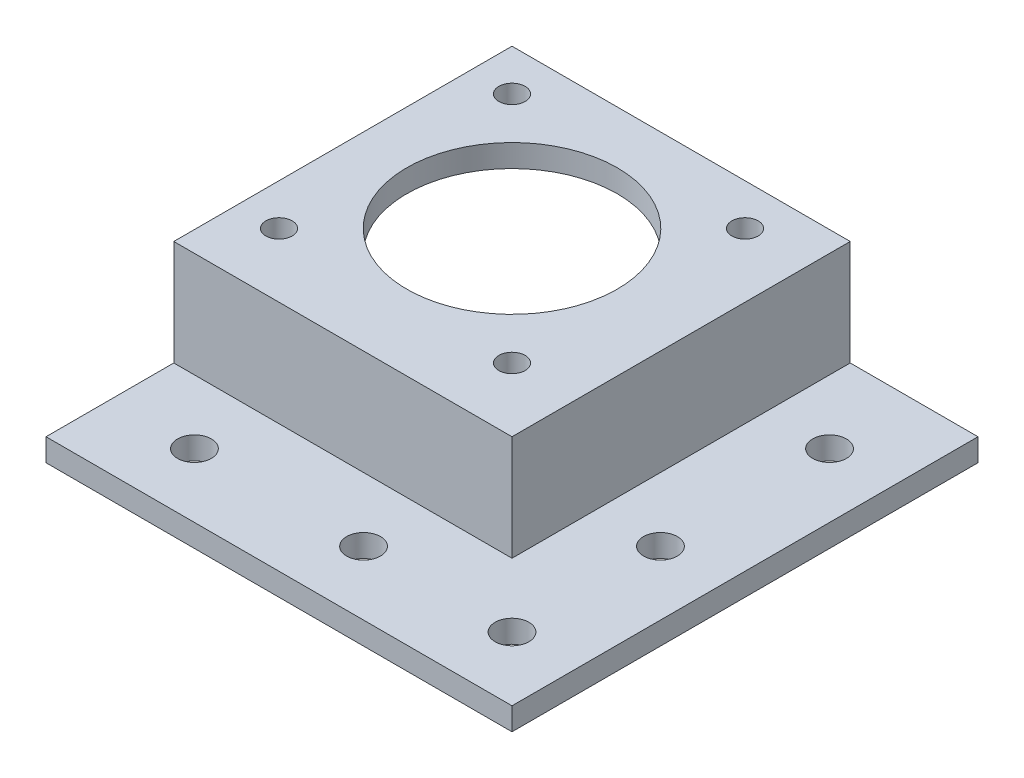
from build123d import *

# Parameters (mm, degrees)
BOSS_EXTRUDE6_DEPTH = 42
SKETCH9_W           = 42
SKETCH9_H           = 14
BOSS_EXTRUDE7_DEPTH = 3
SKETCH10_W          = 62
SKETCH10_H          = 3
BOSS_EXTRUDE8_DEPTH = 17
SKETCH11_R          = 1.75
SKETCH11_R_2        = 14
CUT_EXTRUDE3_DEPTH  = 4
SKETCH12_R          = 2.25
CUT_EXTRUDE4_DEPTH  = 4


with BuildPart() as part:
    # Sketch7 → Boss-Extrude6 (new body)
    with BuildSketch(Plane.XY):
        Polygon((42, -17), (62, -17), (62, -14), (45, -14), (45, 0), (0, 0), (0, -3), (42, -3), align=None)
    extrude(amount=BOSS_EXTRUDE6_DEPTH)

    # Sketch9 → Boss-Extrude7 (add)
    with BuildSketch(Plane.XY.offset(42)):
        with Locations((21, -10)):
            Rectangle(SKETCH9_W, SKETCH9_H)
        Polygon((45, -14), (45, 0), (0, 0), (0, -3), (42, -3), (42, -17), (62, -17), (62, -14), align=None)
    extrude(amount=BOSS_EXTRUDE7_DEPTH)

    # Sketch10 → Boss-Extrude8 (add)
    with BuildSketch(Plane.XY.offset(45)):
        with Locations((31, -15.5)):
            Rectangle(SKETCH10_W, SKETCH10_H)
    extrude(amount=BOSS_EXTRUDE8_DEPTH)

    # Sketch11 → Cut-Extrude3 (cut, through all)
    with BuildSketch(Plane.XZ.offset(3)):
        with Locations((5.5, 36.5)):
            Circle(SKETCH11_R)
        with Locations((36.5, 36.5)):
            Circle(SKETCH11_R)
        with Locations((36.5, 5.5)):
            Circle(SKETCH11_R)
        with Locations((5.5, 5.5)):
            Circle(SKETCH11_R)
        with Locations((21, 21)):
            Circle(SKETCH11_R_2)
    extrude(amount=-CUT_EXTRUDE3_DEPTH, mode=Mode.SUBTRACT)

    # Sketch12 → Cut-Extrude4 (cut, through all)
    with BuildSketch(Plane(origin=(0, -14, 0), x_dir=(1, 0, 0), z_dir=(0, 1, 0))):
        with Locations((11.25, -53.5)):
            Circle(SKETCH12_R)
        with Locations((33.75, -53.5)):
            Circle(SKETCH12_R)
        with Locations((53.5, -53.5)):
            Circle(SKETCH12_R)
        with Locations((53.5, -11.25)):
            Circle(SKETCH12_R)
        with Locations((53.5, -33.75)):
            Circle(SKETCH12_R)
    extrude(amount=-CUT_EXTRUDE4_DEPTH, mode=Mode.SUBTRACT)


solid = part.part
